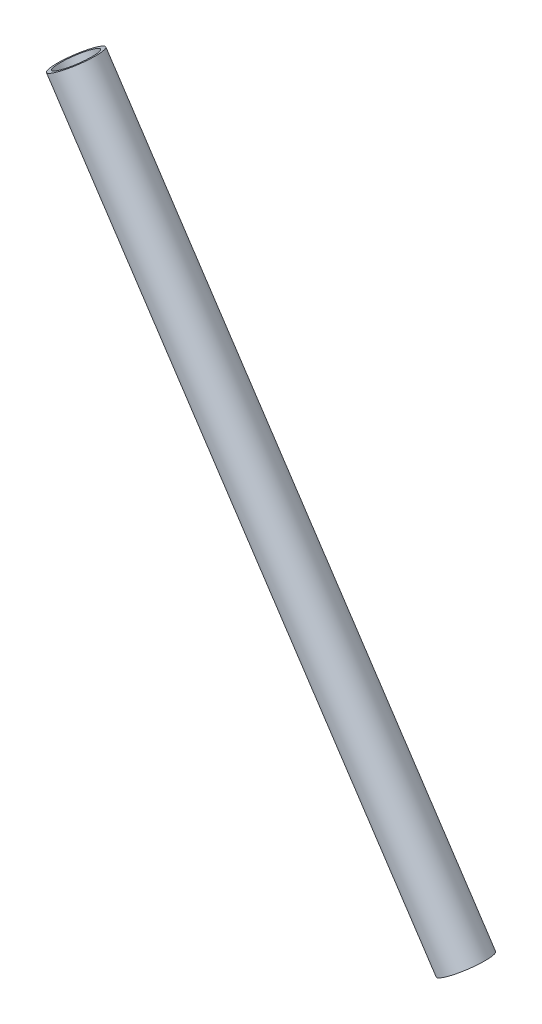
from build123d import *


with BuildPart() as part:
    # Sketch1 → Revolve1 (revolve)
    with BuildSketch(Plane.XY):
        Polygon((473.129567746, 369.002734145), (471.753117467, 368.091040321), (309.543148139, 612.991194255), (310.919598419, 613.902888079), align=None)
    revolve(axis=Axis((317.484207445, 618.250966313, 0), (0.55220704, -0.833707014, 0)))


solid = part.part
